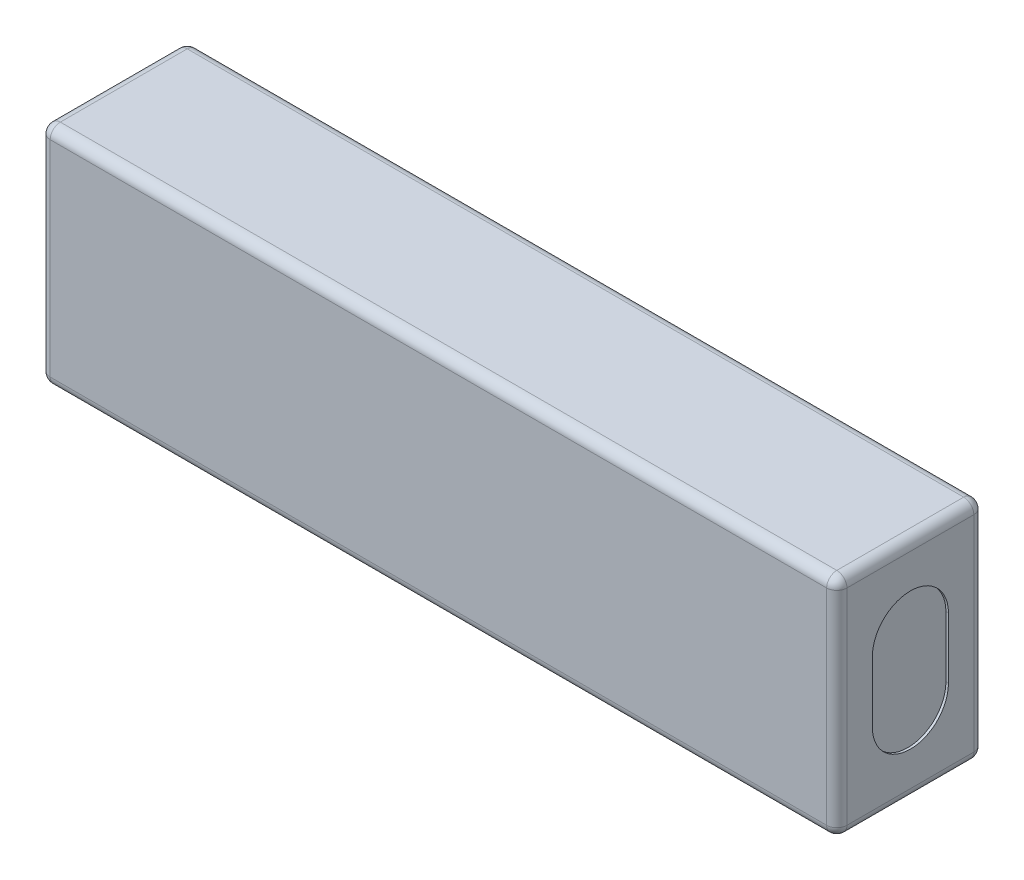
from build123d import *

# Parameters (mm, degrees)
ESBO_O1_W                = 157
ESBO_O1_H                = 44.5
RESSALTO_EXTRUS_O1_DEPTH = 14.5
CORTE_EXTRUS_O1_DEPTH    = 0.5
FILETE1_R                = 2


with BuildPart() as part:
    # Esboço1 → Ressalto-extrusão1 (new body, symmetric)
    with BuildSketch(Plane.XY):
        Rectangle(ESBO_O1_W, ESBO_O1_H)
    extrude(amount=RESSALTO_EXTRUS_O1_DEPTH, both=True)

    # Esboço2 → Corte-extrusão1 (cut)
    with BuildSketch(Plane(origin=(78.5, 0, 0), x_dir=(0, 0, -1), z_dir=(1, 0, 0))):
        with BuildLine():
            Line((7.5, 6), (7.5, -6))
            ThreePointArc((7.5, -6), (0, -13.5), (-7.5, -6))
            Line((-7.5, -6), (-7.5, 6))
            ThreePointArc((-7.5, 6), (0, 13.5), (7.5, 6))
        make_face()
    corte_extrus_o1 = extrude(amount=-CORTE_EXTRUS_O1_DEPTH, mode=Mode.SUBTRACT)

    # Espelhar1: Corte-extrusão1 across plane
    add(corte_extrus_o1.mirror(Plane(origin=(0, 0, 0), x_dir=(0, 0, 1), z_dir=(1, 0, 0))), mode=Mode.SUBTRACT)

    # Filete1
    filete1_edges = [part.edges().sort_by_distance(p)[0] for p in [
        (-78.5, 0, 14.5),
        (0, -22.25, 14.5),
        (78.5, 0, 14.5),
        (0, -22.25, -14.5),
        (-78.5, 0, -14.5),
        (0, 22.25, -14.5),
        (78.5, 0, -14.5),
        (0, 22.25, 14.5),
        (78.5, -22.25, 0),
        (-78.5, -22.25, 0),
        (-78.5, 22.25, 0),
        (78.5, 22.25, 0),
    ]]
    fillet(filete1_edges, radius=FILETE1_R)


solid = part.part
